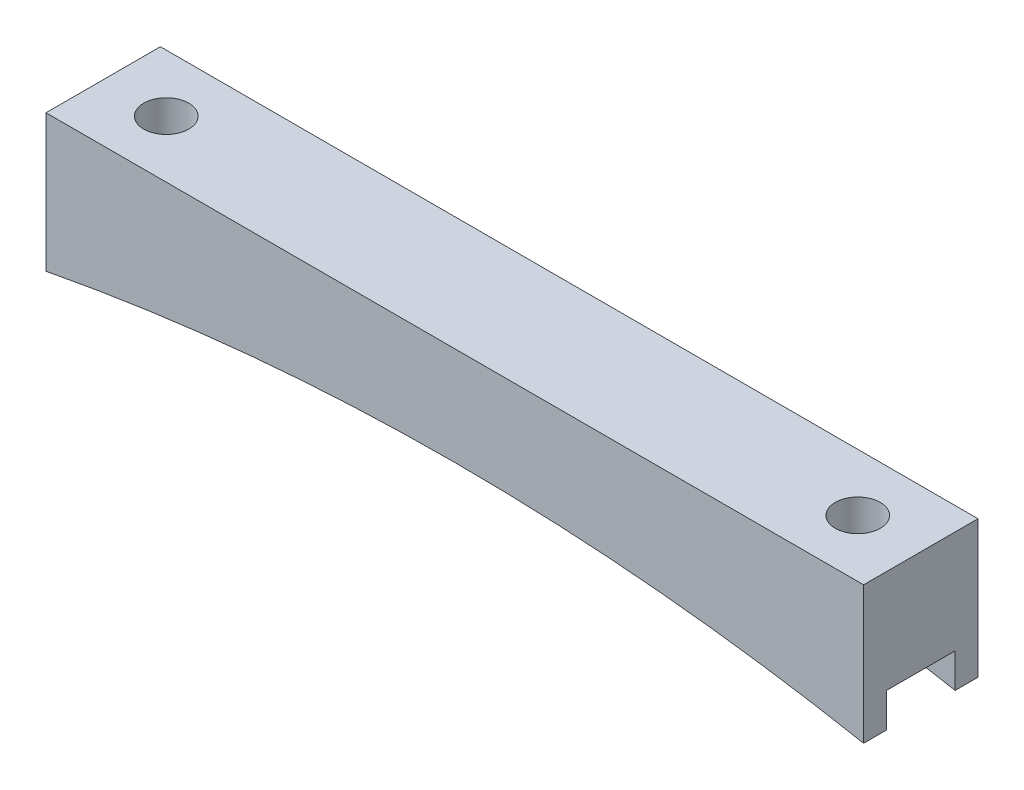
from build123d import *

# Parameters (mm, degrees)
BOSS_EXTRUDE1_DEPTH = 12.7
SKETCH2_R           = 2.5
CUT_EXTRUDE1_DEPTH  = 16.24
SKETCH3_W           = 7.62
SKETCH3_H           = 3.81
CUT_EXTRUDE2_DEPTH  = 91.7700001


with BuildPart() as part:
    # Sketch1 → Boss-Extrude1 (new body)
    with BuildSketch(Plane.XY):
        with BuildLine():
            Line((-45.385, 0), (45.385, 0))
            Line((45.385, 0), (45.385, -15.24))
            ThreePointArc((45.385, -15.24), (0, -10.933442473), (-45.385, -15.24))
            Line((-45.385, -15.24), (-45.385, 0))
        make_face()
    extrude(amount=BOSS_EXTRUDE1_DEPTH)

    # Sketch2 → Cut-Extrude1 (cut, through all)
    with BuildSketch(Plane(origin=(0, 0, 0), x_dir=(1, 0, 0), z_dir=(0, 1, 0))):
        with Locations((-38.385, -6.35)):
            Circle(SKETCH2_R)
        with Locations((38.385, -6.35)):
            Circle(SKETCH2_R)
    extrude(amount=-CUT_EXTRUDE1_DEPTH, mode=Mode.SUBTRACT)

    # Sketch3 → Cut-Extrude2 (cut, through all)
    with BuildSketch(Plane(origin=(45.385, 0, 0), x_dir=(0, 0, -1), z_dir=(1, 0, 0))):
        with Locations((-6.35, -13.335)):
            Rectangle(SKETCH3_W, SKETCH3_H)
    extrude(amount=-CUT_EXTRUDE2_DEPTH, mode=Mode.SUBTRACT)


solid = part.part
